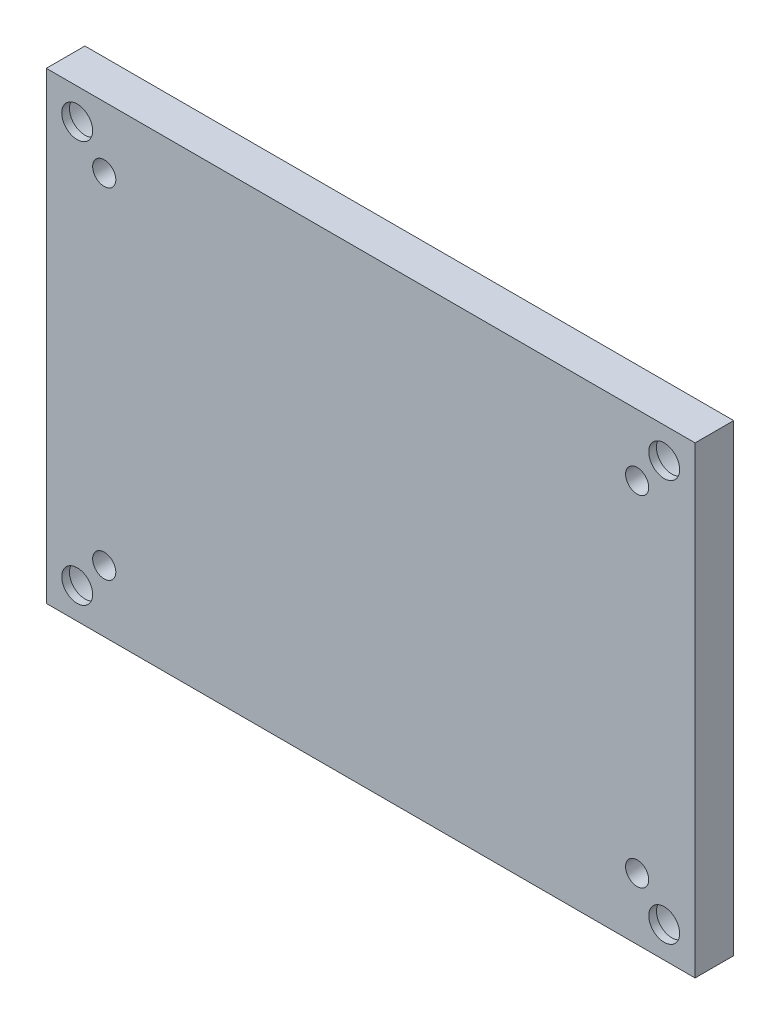
from build123d import *

# Parameters (mm, degrees)
BOSS_EXTRUDE1_DEPTH = 5
SKETCH2_R           = 3.5
CUT_EXTRUDE1_DEPTH  = 4
SKETCH6_R           = 2
CUT_EXTRUDE2_DEPTH  = 5
SKETCH7_R           = 1.5
CUT_EXTRUDE3_DEPTH  = 3
SKETCH8_W           = 0.928571429
SKETCH8_H           = 4
CUT_EXTRUDE4_DEPTH  = 1


with BuildPart() as part:
    # Sketch1 → Boss-Extrude1 (new body)
    with BuildSketch(Plane.XY):
        Polygon((-39, 30), (-42, 30), (-42, 27), (-42, -27), (-42, -30), (-39, -30), (39, -30), (42, -30), (42, -27), (42, 27), (42, 30), (39, 30), align=None)
    extrude(amount=BOSS_EXTRUDE1_DEPTH)

    # Sketch2 → Cut-Extrude1 (cut)
    with BuildSketch(Plane(origin=(0, 0, 0), x_dir=(-1, 0, 0), z_dir=(0, 0, -1))):
        with Locations((38, 26)):
            Circle(SKETCH2_R)
        with Locations((-38, 26)):
            Circle(SKETCH2_R)
        with Locations((-38, -26)):
            Circle(SKETCH2_R)
        with Locations((38, -26)):
            Circle(SKETCH2_R)
    extrude(amount=-CUT_EXTRUDE1_DEPTH, mode=Mode.SUBTRACT)

    # Sketch6 → Cut-Extrude2 (cut)
    with BuildSketch(Plane(origin=(0, 0, 0), x_dir=(-1, 0, 0), z_dir=(0, 0, -1))):
        with Locations((-38, 26)):
            Circle(SKETCH6_R)
        with Locations((38, 26)):
            Circle(SKETCH6_R)
        with Locations((38, -26)):
            Circle(SKETCH6_R)
        with Locations((-38, -26)):
            Circle(SKETCH6_R)
    extrude(amount=-CUT_EXTRUDE2_DEPTH, mode=Mode.SUBTRACT)

    # Sketch7 → Cut-Extrude3 (cut)
    with BuildSketch(Plane.XY.offset(5)):
        with Locations((-34.5, 22)):
            Circle(SKETCH7_R)
        with Locations((34.5, 22)):
            Circle(SKETCH7_R)
        with Locations((34.5, -22)):
            Circle(SKETCH7_R)
        with Locations((-34.5, -22)):
            Circle(SKETCH7_R)
    extrude(amount=-CUT_EXTRUDE3_DEPTH, mode=Mode.SUBTRACT)

    # Sketch8 → Cut-Extrude4 (cut)
    with BuildSketch(Plane(origin=(0, 0, 0), x_dir=(-1, 0, 0), z_dir=(0, 0, -1))):
        with BuildLine():
            Line((-32.923042146, -1.522187789), (-32.923042146, 2.477812211))
            Line((-32.923042146, 2.477812211), (-32.13732786, 2.477812211))
            Line((-32.13732786, 2.477812211), (-30.273488575, 0.072678283))
            Line((-30.273488575, 0.072678283), (-28.447595718, 2.477812211))
            Line((-28.447595718, 2.477812211), (-27.708756432, 2.477812211))
            Line((-27.708756432, 2.477812211), (-27.708756432, -1.522187789))
            Line((-27.708756432, -1.522187789), (-28.565899289, -1.522187789))
            Line((-28.565899289, -1.522187789), (-28.565899289, 0.957722926))
            add(Edge.make_bspline(
                [(-28.565899289, 0.957722926), (-28.565373952, 0.984889613), (-28.564206922, 1.045240059), (-28.556964931, 1.144239826), (-28.545486632, 1.258731815), (-28.536918258, 1.340166906), (-28.532417146, 1.38294614)],
                knots=[0, 0, 0, 0, 8.1504e-05, 0.00018106, 0.000297666, 0.000426711, 0.000426711, 0.000426711, 0.000426711], degree=3))
            add(Edge.make_bspline(
                [(-28.532417146, 1.38294614), (-28.555447489, 1.335487291), (-28.597303302, 1.249234617), (-28.659873398, 1.134493623), (-28.712329595, 1.041205061), (-28.748246193, 0.988402844), (-28.764560003, 0.964419354)],
                knots=[0, 0, 0, 0, 0.000158223, 0.000287557, 0.000392075, 0.000479057, 0.000479057, 0.000479057, 0.000479057], degree=3))
            Line((-28.764560003, 0.964419354), (-30.251167146, -1.022187789))
            Line((-30.251167146, -1.022187789), (-30.43420286, -1.022187789))
            Line((-30.43420286, -1.022187789), (-31.924158218, 0.972231854))
            add(Edge.make_bspline(
                [(-31.924158218, 0.972231854), (-31.949729196, 1.008497751), (-31.99861494, 1.077829684), (-32.064756996, 1.180803564), (-32.117104715, 1.280755949), (-32.146572395, 1.346713649), (-32.16076536, 1.378481854)],
                knots=[0, 0, 0, 0, 0.000133126, 0.000254506, 0.000366837, 0.000471212, 0.000471212, 0.000471212, 0.000471212], degree=3))
            add(Edge.make_bspline(
                [(-32.16076536, 1.378481854), (-32.156721617, 1.339072715), (-32.14902469, 1.264060721), (-32.143006049, 1.155675735), (-32.137673542, 1.054874031), (-32.137441727, 0.989724124), (-32.13732786, 0.957722926)],
                knots=[0, 0, 0, 0, 0.000118829, 0.000226181, 0.000325611, 0.0004216, 0.0004216, 0.0004216, 0.0004216], degree=3))
            Line((-32.13732786, 0.957722926), (-32.13732786, -1.522187789))
            Line((-32.13732786, -1.522187789), (-32.923042146, -1.522187789))
        make_face()
        Polygon((-26.494470718, -1.522187789), (-24.241122503, 2.477812211), (-23.349381432, 2.477812211), (-21.065899289, -1.522187789), (-22.10607786, -1.522187789), (-22.583756432, -0.665044931), (-25.108310003, -0.665044931), (-25.571479646, -1.522187789), align=None)
        Polygon((-24.712104646, 0.049240783), (-22.968801075, 0.049240783), (-23.827060003, 1.694330069), align=None, mode=Mode.SUBTRACT)
        with BuildLine():
            Line((-19.851613575, -1.522187789), (-19.851613575, 2.477812211))
            Line((-19.851613575, 2.477812211), (-17.26232786, 2.477812211))
            add(Edge.make_bspline(
                [(-17.26232786, 2.477812211), (-17.173721749, 2.476524828), (-17.001726968, 2.474025867), (-16.751508425, 2.448628561), (-16.517113034, 2.409230034), (-16.297960096, 2.353865445), (-16.095203465, 2.280968118), (-15.907465424, 2.193387025), (-15.736646659, 2.087186207), (-15.58107702, 1.966726001), (-15.44161097, 1.831536697), (-15.322001825, 1.681064979), (-15.220239213, 1.517488951), (-15.13811155, 1.340333138), (-15.072408188, 1.150161436), (-15.027820099, 0.945994949), (-14.998889601, 0.728642418), (-14.995969244, 0.579100429), (-14.994470718, 0.502365783)],
                knots=[0, 0, 0, 0, 0.00026574, 0.000515832, 0.000753626, 0.0009783, 0.00119294, 0.001399127, 0.001598588, 0.001795046, 0.00198841, 0.002179792, 0.002370262, 0.002564983, 0.002764398, 0.002972613, 0.003190922, 0.003421006, 0.003421006, 0.003421006, 0.003421006], degree=3))
            add(Edge.make_bspline(
                [(-14.994470718, 0.502365783), (-14.997251116, 0.411058919), (-15.002695717, 0.232260991), (-15.045683588, -0.029173422), (-15.118587835, -0.276019575), (-15.2190053, -0.507319088), (-15.344451301, -0.720027966), (-15.496193846, -0.909589143), (-15.670269402, -1.077154115), (-15.803668161, -1.166899658), (-15.870586789, -1.211919931)],
                knots=[0, 0, 0, 0, 0.000273822, 0.000536201, 0.000792229, 0.001044148, 0.00129087, 0.001530709, 0.001770703, 0.00201228, 0.00201228, 0.00201228, 0.00201228], degree=3))
            add(Edge.make_bspline(
                [(-15.870586789, -1.211919931), (-15.916212122, -1.238210221), (-16.009834134, -1.292157219), (-16.164776486, -1.356309721), (-16.334781491, -1.40960347), (-16.52257992, -1.45193318), (-16.731004698, -1.484233277), (-16.964741157, -1.505203043), (-17.224927436, -1.520360259), (-17.407763631, -1.52156016), (-17.503399289, -1.522187789)],
                knots=[0, 0, 0, 0, 0.000157836, 0.000323876, 0.000501777, 0.000691837, 0.000900831, 0.001134045, 0.001395608, 0.001682473, 0.001682473, 0.001682473, 0.001682473], degree=3))
            Line((-17.503399289, -1.522187789), (-19.851613575, -1.522187789))
        make_face()
        with BuildLine():
            Line((-18.923042146, -0.736473503), (-17.706524289, -0.736473503))
            add(Edge.make_bspline(
                [(-17.706524289, -0.736473503), (-17.628367643, -0.735838791), (-17.477860341, -0.734616516), (-17.261209185, -0.719154587), (-17.062008391, -0.698258295), (-16.880862825, -0.665747978), (-16.716697089, -0.62522933), (-16.570716917, -0.574084344), (-16.441400478, -0.51512411), (-16.329008333, -0.445633847), (-16.232812715, -0.36362248), (-16.14912792, -0.271220442), (-16.078177062, -0.16656309), (-16.02139383, -0.049019336), (-15.976616519, 0.079781649), (-15.945992297, 0.220688331), (-15.926752919, 0.37311453), (-15.924307933, 0.478866988), (-15.923042146, 0.533615783)],
                knots=[0, 0, 0, 0, 0.000234418, 0.000451421, 0.000651332, 0.000835009, 0.001003107, 0.001158064, 0.001298374, 0.001428745, 0.00155307, 0.001676344, 0.001801713, 0.001930989, 0.00206688, 0.002209846, 0.002362813, 0.002527012, 0.002527012, 0.002527012, 0.002527012], degree=3))
            add(Edge.make_bspline(
                [(-15.923042146, 0.533615783), (-15.924112008, 0.58276959), (-15.926184503, 0.677988508), (-15.942180832, 0.816081491), (-15.967240716, 0.945178585), (-16.004100898, 1.065351937), (-16.052029015, 1.176176002), (-16.110612752, 1.277546957), (-16.179010615, 1.370173353), (-16.258978923, 1.452870267), (-16.348521858, 1.527122271), (-16.448517978, 1.590577416), (-16.5579508, 1.644972558), (-16.678084793, 1.687746697), (-16.807886995, 1.722624182), (-16.947972255, 1.746676357), (-17.097944891, 1.761421446), (-17.201279913, 1.76281076), (-17.25451536, 1.763526497)],
                knots=[0, 0, 0, 0, 0.000147427, 0.00028559, 0.00041648, 0.00054145, 0.000661914, 0.000777921, 0.000891984, 0.00100644, 0.001122189, 0.001240145, 0.001360933, 0.001488038, 0.001622046, 0.001763699, 0.001913954, 0.002073615, 0.002073615, 0.002073615, 0.002073615], degree=3))
            Line((-17.25451536, 1.763526497), (-18.923042146, 1.763526497))
            Line((-18.923042146, 1.763526497), (-18.923042146, -0.736473503))
        make_face(mode=Mode.SUBTRACT)
        Polygon((-13.351613575, -1.522187789), (-13.351613575, 2.477812211), (-9.280185003, 2.477812211), (-9.280185003, 1.763526497), (-12.423042146, 1.763526497), (-12.423042146, 0.977812211), (-10.565899289, 0.977812211), (-10.565899289, 0.263526497), (-12.423042146, 0.263526497), (-12.423042146, -0.736473503), (-9.208756432, -0.736473503), (-9.208756432, -1.522187789), align=None)
        with Locations((-4.030185004, 0.477812211)):
            Rectangle(SKETCH8_W, SKETCH8_H)
        with BuildLine():
            Line((-1.565899289, -1.522187789), (-1.565899289, 2.477812211))
            Line((-1.565899289, 2.477812211), (-0.930854646, 2.477812211))
            Line((-0.930854646, 2.477812211), (1.879413211, 0.120669354))
            add(Edge.make_bspline(
                [(1.879413211, 0.120669354), (1.92443739, 0.083153519), (2.010327523, 0.011586638), (2.128216493, -0.098427441), (2.23610311, -0.203715866), (2.299223461, -0.278012376), (2.330306068, -0.314598503)],
                knots=[0, 0, 0, 0, 0.000175773, 0.000335313, 0.000483679, 0.000627622, 0.000627622, 0.000627622, 0.000627622], degree=3))
            add(Edge.make_bspline(
                [(2.330306068, -0.314598503), (2.326313591, -0.262532988), (2.318958677, -0.166618253), (2.312686923, -0.035119347), (2.303427911, 0.071485103), (2.298446141, 0.17571806), (2.293272773, 0.27501322), (2.291848465, 0.346854932), (2.291243568, 0.377365783)],
                knots=[0, 0, 0, 0, 0.000156648, 0.000288576, 0.00039489, 0.0004776, 0.00060161, 0.000693155, 0.000693155, 0.000693155, 0.000693155], degree=3))
            Line((2.291243568, 0.377365783), (2.291243568, 2.477812211))
            Line((2.291243568, 2.477812211), (3.148386425, 2.477812211))
            Line((3.148386425, 2.477812211), (3.148386425, -1.522187789))
            Line((3.148386425, -1.522187789), (2.514457854, -1.522187789))
            Line((2.514457854, -1.522187789), (-0.416345718, 0.948794354))
            add(Edge.make_bspline(
                [(-0.416345718, 0.948794354), (-0.449075465, 0.97893525), (-0.510653123, 1.035642249), (-0.598867971, 1.116656881), (-0.676450668, 1.195479077), (-0.724197943, 1.248471435), (-0.747818932, 1.274687211)],
                knots=[0, 0, 0, 0, 0.000133486, 0.00025114, 0.000359261, 0.000465117, 0.000465117, 0.000465117, 0.000465117], degree=3))
            add(Edge.make_bspline(
                [(-0.747818932, 1.274687211), (-0.741331482, 1.214834966), (-0.72869607, 1.098262541), (-0.719300176, 0.930231506), (-0.709964726, 0.778133765), (-0.709139701, 0.68280972), (-0.708756432, 0.638526497)],
                knots=[0, 0, 0, 0, 0.000180573, 0.000351696, 0.000504797, 0.000637628, 0.000637628, 0.000637628, 0.000637628], degree=3))
            Line((-0.708756432, 0.638526497), (-0.708756432, -1.522187789))
            Line((-0.708756432, -1.522187789), (-1.565899289, -1.522187789))
        make_face()
        with Locations((8.612672139, 0.477812211)):
            Rectangle(SKETCH8_W, SKETCH8_H)
        with BuildLine():
            Line((11.076957854, -1.522187789), (11.076957854, 2.477812211))
            Line((11.076957854, 2.477812211), (11.712002497, 2.477812211))
            Line((11.712002497, 2.477812211), (14.522270354, 0.120669354))
            add(Edge.make_bspline(
                [(14.522270354, 0.120669354), (14.567294533, 0.083153519), (14.653184666, 0.011586638), (14.771073636, -0.098427441), (14.878960252, -0.203715866), (14.942080604, -0.278012376), (14.973163211, -0.314598503)],
                knots=[0, 0, 0, 0, 0.000175773, 0.000335313, 0.000483679, 0.000627622, 0.000627622, 0.000627622, 0.000627622], degree=3))
            add(Edge.make_bspline(
                [(14.973163211, -0.314598503), (14.969170734, -0.262532988), (14.96181582, -0.166618253), (14.955544066, -0.035119347), (14.946285054, 0.071485103), (14.941303284, 0.17571806), (14.936129916, 0.27501322), (14.934705608, 0.346854932), (14.934100711, 0.377365783)],
                knots=[0, 0, 0, 0, 0.000156648, 0.000288576, 0.00039489, 0.0004776, 0.00060161, 0.000693155, 0.000693155, 0.000693155, 0.000693155], degree=3))
            Line((14.934100711, 0.377365783), (14.934100711, 2.477812211))
            Line((14.934100711, 2.477812211), (15.791243568, 2.477812211))
            Line((15.791243568, 2.477812211), (15.791243568, -1.522187789))
            Line((15.791243568, -1.522187789), (15.157314997, -1.522187789))
            Line((15.157314997, -1.522187789), (12.226511425, 0.948794354))
            add(Edge.make_bspline(
                [(12.226511425, 0.948794354), (12.193781678, 0.97893525), (12.13220402, 1.035642249), (12.043989171, 1.116656881), (11.966406475, 1.195479077), (11.9186592, 1.248471435), (11.895038211, 1.274687211)],
                knots=[0, 0, 0, 0, 0.000133486, 0.00025114, 0.000359261, 0.000465117, 0.000465117, 0.000465117, 0.000465117], degree=3))
            add(Edge.make_bspline(
                [(11.895038211, 1.274687211), (11.901525661, 1.214834966), (11.914161073, 1.098262541), (11.923556967, 0.930231506), (11.932892416, 0.778133765), (11.933717442, 0.68280972), (11.934100711, 0.638526497)],
                knots=[0, 0, 0, 0, 0.000180573, 0.000351696, 0.000504797, 0.000637628, 0.000637628, 0.000637628, 0.000637628], degree=3))
            Line((11.934100711, 0.638526497), (11.934100711, -1.522187789))
            Line((11.934100711, -1.522187789), (11.076957854, -1.522187789))
        make_face()
        with BuildLine():
            Line((17.791243568, -1.522187789), (17.791243568, 2.477812211))
            Line((17.791243568, 2.477812211), (20.380529282, 2.477812211))
            add(Edge.make_bspline(
                [(20.380529282, 2.477812211), (20.469135394, 2.476524828), (20.641130175, 2.474025867), (20.891348717, 2.448628561), (21.125744109, 2.409230034), (21.344897047, 2.353865445), (21.547653678, 2.280968118), (21.735391719, 2.193387025), (21.906210484, 2.087186207), (22.061780123, 1.966726001), (22.201246173, 1.831536697), (22.320855318, 1.681064979), (22.42261793, 1.517488951), (22.504745593, 1.340333138), (22.570448955, 1.150161436), (22.615037044, 0.945994949), (22.643967541, 0.728642418), (22.646887899, 0.579100429), (22.648386425, 0.502365783)],
                knots=[0, 0, 0, 0, 0.00026574, 0.000515832, 0.000753626, 0.0009783, 0.00119294, 0.001399127, 0.001598588, 0.001795046, 0.00198841, 0.002179792, 0.002370262, 0.002564983, 0.002764398, 0.002972613, 0.003190922, 0.003421006, 0.003421006, 0.003421006, 0.003421006], degree=3))
            add(Edge.make_bspline(
                [(22.648386425, 0.502365783), (22.645606027, 0.411058919), (22.640161426, 0.232260991), (22.597173555, -0.029173422), (22.524269308, -0.276019575), (22.423851843, -0.507319088), (22.298405841, -0.720027966), (22.146663296, -0.909589143), (21.972587741, -1.077154115), (21.839188981, -1.166899658), (21.772270354, -1.211919931)],
                knots=[0, 0, 0, 0, 0.000273822, 0.000536201, 0.000792229, 0.001044148, 0.00129087, 0.001530709, 0.001770703, 0.00201228, 0.00201228, 0.00201228, 0.00201228], degree=3))
            add(Edge.make_bspline(
                [(21.772270354, -1.211919931), (21.726645021, -1.238210221), (21.633023009, -1.292157219), (21.478080656, -1.356309721), (21.308075652, -1.40960347), (21.120277223, -1.45193318), (20.911852445, -1.484233277), (20.678115986, -1.505203043), (20.417929707, -1.520360259), (20.235093511, -1.52156016), (20.139457854, -1.522187789)],
                knots=[0, 0, 0, 0, 0.000157836, 0.000323876, 0.000501777, 0.000691837, 0.000900831, 0.001134045, 0.001395608, 0.001682473, 0.001682473, 0.001682473, 0.001682473], degree=3))
            Line((20.139457854, -1.522187789), (17.791243568, -1.522187789))
        make_face()
        with BuildLine():
            Line((18.719814997, -0.736473503), (19.936332854, -0.736473503))
            add(Edge.make_bspline(
                [(19.936332854, -0.736473503), (20.0144895, -0.735838791), (20.164996802, -0.734616516), (20.381647958, -0.719154587), (20.580848752, -0.698258295), (20.761994318, -0.665747978), (20.926160054, -0.62522933), (21.072140226, -0.574084344), (21.201456665, -0.51512411), (21.31384881, -0.445633847), (21.410044428, -0.36362248), (21.493729223, -0.271220442), (21.564680081, -0.16656309), (21.621463313, -0.049019336), (21.666240624, 0.079781649), (21.696864846, 0.220688331), (21.716104224, 0.37311453), (21.71854921, 0.478866988), (21.719814997, 0.533615783)],
                knots=[0, 0, 0, 0, 0.000234418, 0.000451421, 0.000651332, 0.000835009, 0.001003107, 0.001158064, 0.001298374, 0.001428745, 0.00155307, 0.001676344, 0.001801713, 0.001930989, 0.00206688, 0.002209846, 0.002362813, 0.002527012, 0.002527012, 0.002527012, 0.002527012], degree=3))
            add(Edge.make_bspline(
                [(21.719814997, 0.533615783), (21.718745135, 0.58276959), (21.71667264, 0.677988508), (21.700676311, 0.816081491), (21.675616427, 0.945178585), (21.638756245, 1.065351937), (21.590828127, 1.176176002), (21.532244391, 1.277546957), (21.463846528, 1.370173353), (21.38387822, 1.452870267), (21.294335285, 1.527122271), (21.194339165, 1.590577416), (21.084906343, 1.644972558), (20.96477235, 1.687746697), (20.834970148, 1.722624182), (20.694884888, 1.746676357), (20.544912252, 1.761421446), (20.44157723, 1.76281076), (20.388341782, 1.763526497)],
                knots=[0, 0, 0, 0, 0.000147427, 0.00028559, 0.00041648, 0.00054145, 0.000661914, 0.000777921, 0.000891984, 0.00100644, 0.001122189, 0.001240145, 0.001360933, 0.001488038, 0.001622046, 0.001763699, 0.001913954, 0.002073615, 0.002073615, 0.002073615, 0.002073615], degree=3))
            Line((20.388341782, 1.763526497), (18.719814997, 1.763526497))
            Line((18.719814997, 1.763526497), (18.719814997, -0.736473503))
        make_face(mode=Mode.SUBTRACT)
        with Locations((24.755529282, 0.477812211)):
            Rectangle(SKETCH8_W, SKETCH8_H)
        Polygon((26.505529282, -1.522187789), (28.758877497, 2.477812211), (29.650618568, 2.477812211), (31.934100711, -1.522187789), (30.89392214, -1.522187789), (30.416243568, -0.665044931), (27.891689997, -0.665044931), (27.428520354, -1.522187789), align=None)
        Polygon((28.287895354, 0.049240783), (30.031198925, 0.049240783), (29.172939997, 1.694330069), align=None, mode=Mode.SUBTRACT)
    extrude(amount=-CUT_EXTRUDE4_DEPTH, mode=Mode.SUBTRACT)


solid = part.part
